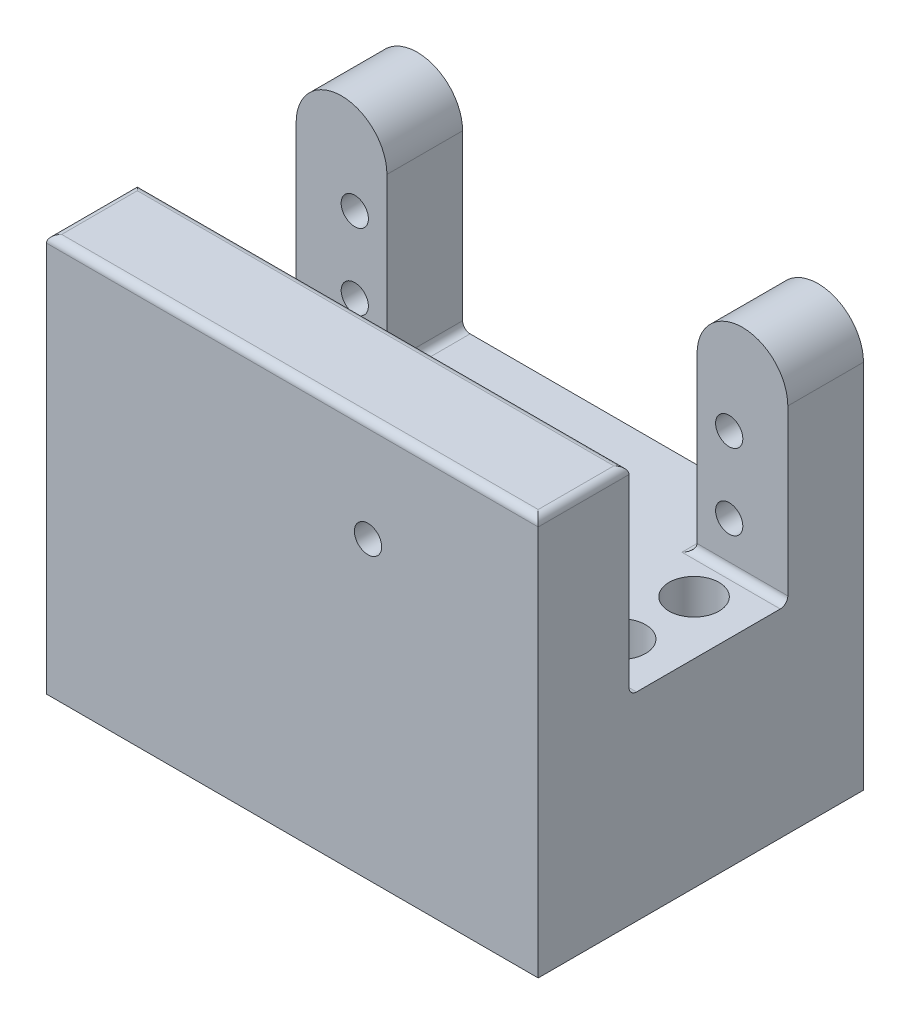
from build123d import *

# Parameters (mm, degrees)
BOSS_EXTRUDE1_DEPTH            = 10
SKETCH2_W                      = 12
SKETCH2_H                      = 12.25
BOSS_EXTRUDE2_DEPTH            = 21
SKETCH4_W                      = 65
SKETCH4_H                      = 38.636969104
BOSS_EXTRUDE3_DEPTH            = 12
F_3_6_3_6_DIAMETER_HOLE1_D     = 3.6
F_3_6_3_6_DIAMETER_HOLE1_DEPTH = 10
F_3_6_3_6_DIAMETER_HOLE1_TIP   = 1.081549114
F_3_6_3_6_DIAMETER_HOLE2_D     = 3.6
F_3_6_3_6_DIAMETER_HOLE2_DEPTH = 12
F_3_6_3_6_DIAMETER_HOLE2_TIP   = 1.081549114
SKETCH21_W                     = 41
SKETCH21_H                     = 12.25
BOSS_EXTRUDE4_DEPTH            = 31
SKETCH23_W                     = 65
SKETCH23_H                     = 43
BOSS_EXTRUDE6_DEPTH            = 14
F_6_6_6_6_DIAMETER_HOLE1_D     = 6.6
FILLET1_R                      = 1


with BuildPart() as part:
    # Sketch1 → Boss-Extrude1 (new body)
    with BuildSketch(Plane.XY):
        with BuildLine():
            Line((-6, 14.302325581), (-6, -20.697674419))
            Line((-6, -20.697674419), (6, -20.697674419))
            Line((6, -20.697674419), (6, 14.302325581))
            ThreePointArc((6, 14.302325581), (0, 20.302325581), (-6, 14.302325581))
        make_face()
    boss_extrude1 = extrude(amount=BOSS_EXTRUDE1_DEPTH)

    # Sketch2 → Boss-Extrude2 (add)
    with BuildSketch(Plane.XY.offset(10)):
        with Locations((0, -14.572674419)):
            Rectangle(SKETCH2_W, SKETCH2_H)
    boss_extrude2 = extrude(amount=BOSS_EXTRUDE2_DEPTH)

    # Sketch4 → Boss-Extrude3 (add)
    with BuildSketch(Plane.XY.offset(31)):
        with Locations((-26.5, -1.379189867)):
            Rectangle(SKETCH4_W, SKETCH4_H)
    extrude(amount=BOSS_EXTRUDE3_DEPTH)

    # Mirror2: Boss-Extrude2 across plane
    add(boss_extrude2.mirror(Plane.ZY.offset(26.5)))

    # Mirror3: Boss-Extrude1 across plane
    add(boss_extrude1.mirror(Plane.ZY.offset(26.5)))

    # Ø3.6 (3.6) Diameter Hole1
    with Locations(Plane(origin=(0, 0, 0), x_dir=(-1, 0, 0), z_dir=(0, 0, -1))):
        with Locations((1.75, 7.55218084), (1.75, -2.44781916), (51.25, 8), (51.25, -2)):
            Hole(F_3_6_3_6_DIAMETER_HOLE1_D / 2, depth=F_3_6_3_6_DIAMETER_HOLE1_DEPTH)
            with Locations((0, 0, -(F_3_6_3_6_DIAMETER_HOLE1_DEPTH + F_3_6_3_6_DIAMETER_HOLE1_TIP / 2))):  # 118° drill point
                Cone(0, F_3_6_3_6_DIAMETER_HOLE1_D / 2, F_3_6_3_6_DIAMETER_HOLE1_TIP, mode=Mode.SUBTRACT)

    # Ø3.6 (3.6) Diameter Hole2
    with Locations(Plane.XY.offset(43)):
        with Locations((-16.499999995, 4.313158503)):
            Hole(F_3_6_3_6_DIAMETER_HOLE2_D / 2, depth=F_3_6_3_6_DIAMETER_HOLE2_DEPTH)
            with Locations((0, 0, -(F_3_6_3_6_DIAMETER_HOLE2_DEPTH + F_3_6_3_6_DIAMETER_HOLE2_TIP / 2))):  # 118° drill point
                Cone(0, F_3_6_3_6_DIAMETER_HOLE2_D / 2, F_3_6_3_6_DIAMETER_HOLE2_TIP, mode=Mode.SUBTRACT)

    # Sketch21 → Boss-Extrude4 (add)
    with BuildSketch(Plane(origin=(0, 0, 31), x_dir=(-1, 0, 0), z_dir=(0, 0, -1))):
        with Locations((26.5, -14.572674419)):
            Rectangle(SKETCH21_W, SKETCH21_H)
    extrude(amount=BOSS_EXTRUDE4_DEPTH)

    # Sketch23 → Boss-Extrude6 (add)
    with BuildSketch(Plane.XZ.offset(20.697674419)):
        with Locations((-26.5, 21.5)):
            Rectangle(SKETCH23_W, SKETCH23_H)
    extrude(amount=BOSS_EXTRUDE6_DEPTH)

    # Ø6.6 (6.6) Diameter Hole1 (through all)
    with Locations(Plane(origin=(0, -34.697674419, 0), x_dir=(-1, 0, 0), z_dir=(0, -1, 0))):
        with Locations((1.1, -15.3), (1.1, -25), (51.9, -15.3), (51.9, -25)):
            Hole(F_6_6_6_6_DIAMETER_HOLE1_D / 2)

    # Fillet1
    fillet1_edges = [part.edges().sort_by_distance(p)[0] for p in [
        (-26.5, -8.447674419, 31),
        (0, -8.447674419, 10),
        (-26.5, 17.939294685, 31),
        (6, 17.939294685, 37),
        (-59, 17.939294685, 37),
        (-26.5, 17.939294685, 43),
        (-53, -8.447674419, 10),
        (-6, -8.447674419, 5),
        (-47, -8.447674419, 5),
    ]]
    fillet(fillet1_edges, radius=FILLET1_R)


solid = part.part
